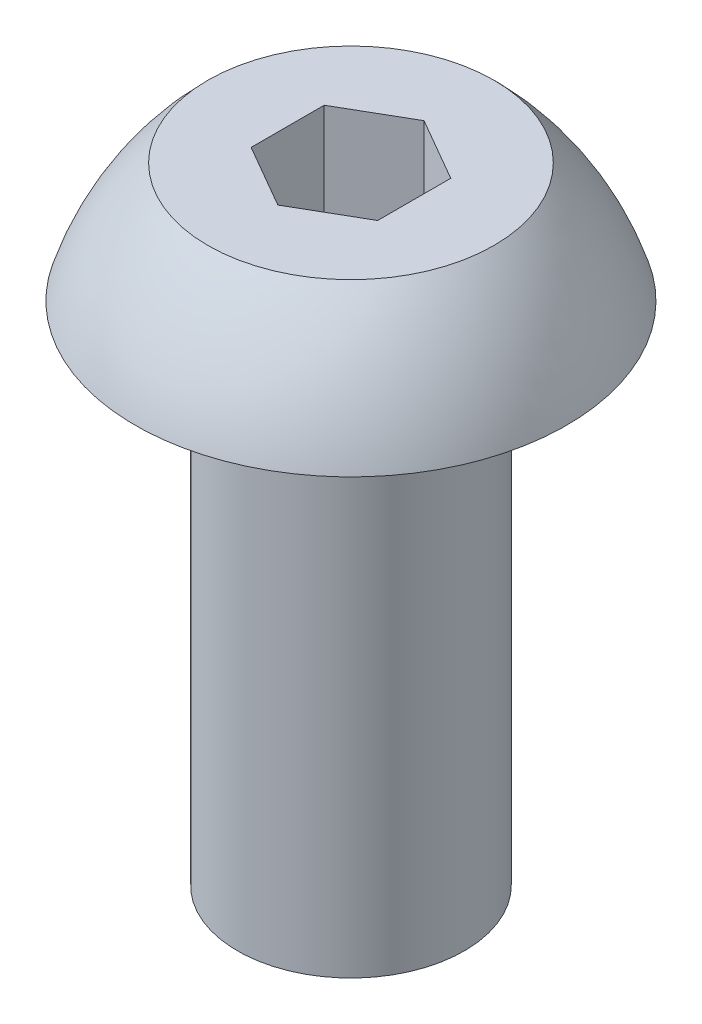
from build123d import *

# Parameters (mm, degrees)
CUT_EXTRUDE1_DEPTH = 1.27


with BuildPart() as part:
    # Sketch1 → Revolve1 (revolve)
    with BuildSketch(Plane.XY):
        with BuildLine():
            Line((-1.4224, 0), (-2.7051, 0))
            ThreePointArc((-2.7051, 0), (-2.343607569, 0.806201731), (-1.79477003, 1.4986))
            Line((-1.79477003, 1.4986), (0, 1.4986))
            Line((0, 1.4986), (0, -6.35))
            Line((0, -6.35), (-1.4224, -6.35))
            Line((-1.4224, -6.35), (-1.4224, 0))
        make_face()
    revolve(axis=Axis((0, -6.35, 0), (0, 1, 0)))

    # Sketch2 → Cut-Extrude1 (cut)
    with BuildSketch(Plane(origin=(0, 1.4986, 0), x_dir=(1, 0, 0), z_dir=(0, 1, 0))):
        Polygon((-0.79375, 0.458271776), (-0.79375, -0.458271776), (0, -0.916543552), (0.79375, -0.458271776), (0.79375, 0.458271776), (0, 0.916543552), align=None)
    extrude(amount=-CUT_EXTRUDE1_DEPTH, mode=Mode.SUBTRACT)


solid = part.part
